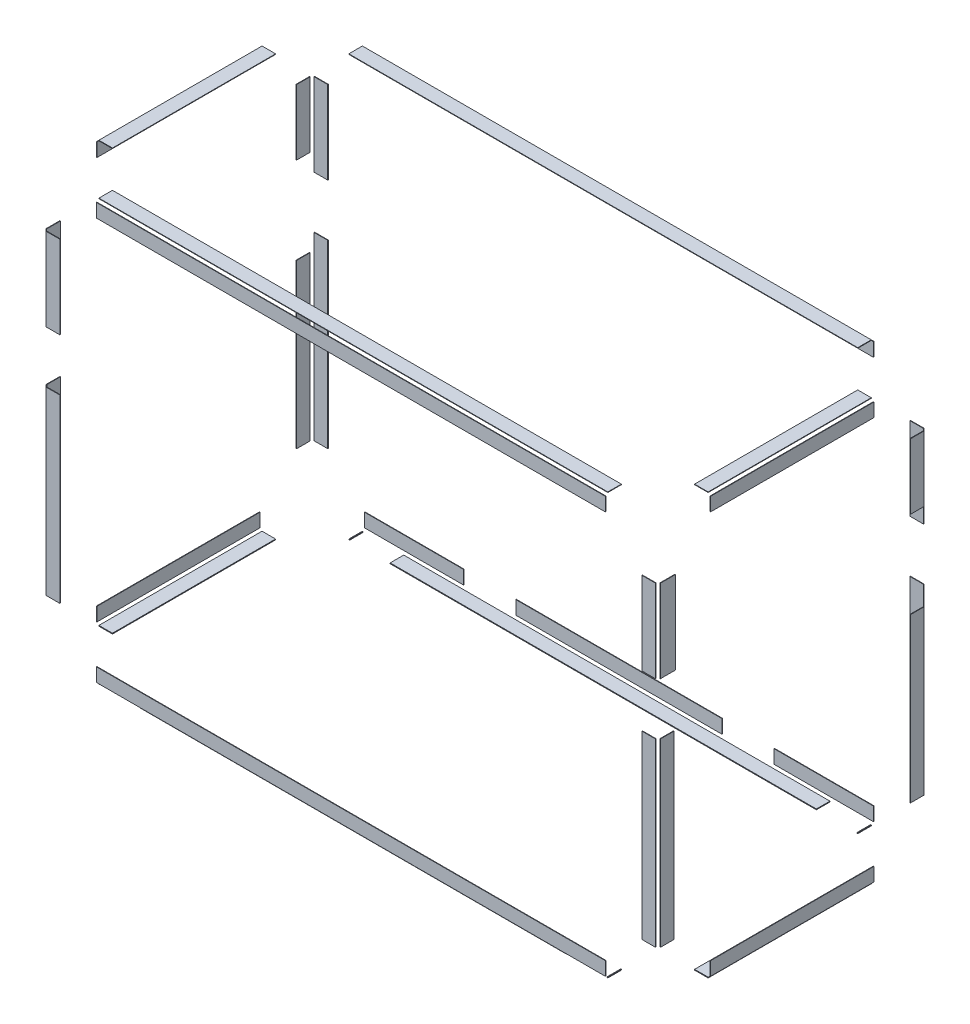
from build123d import *

# Parameters (mm, degrees)
SKETCH1_W              = 506.684
SKETCH1_H              = 42.1005
BOSS_EXTRUDE1_DEPTH    = 1.5875
SKETCH1_W_2            = 42.1005
SKETCH1_H_2            = 203.1375
BOSS_EXTRUDE1_2_DEPTH  = 1.5875
SKETCH1_W_3            = 47.107097302
SKETCH1_H_3            = 257.1125
BOSS_EXTRUDE1_3_DEPTH  = 1.5875
SKETCH1_H_4            = 560.4685
BOSS_EXTRUDE1_4_DEPTH  = 1.5875
SKETCH1_W_4            = 506.683999998
BOSS_EXTRUDE1_5_DEPTH  = 1.5875
SKETCH1_H_5            = 506.4935
BOSS_EXTRUDE1_6_DEPTH  = 1.5875
SKETCH2_W              = 1580.506
SKETCH2_H              = 42.1005
BOSS_EXTRUDE2_DEPTH    = 1.5875
BOSS_EXTRUDE2_2_DEPTH  = 1.5875
SKETCH2_W_2            = 42.1005
SKETCH2_H_2            = 257.1125
BOSS_EXTRUDE2_3_DEPTH  = 1.5875
SKETCH2_H_3            = 560.4685
BOSS_EXTRUDE2_4_DEPTH  = 1.5875
BOSS_EXTRUDE2_5_DEPTH  = 1.5875
BOSS_EXTRUDE2_6_DEPTH  = 1.5875
SKETCH3_W              = 506.684
SKETCH3_H              = 42.1005
BOSS_EXTRUDE3_DEPTH    = 1.5875
SKETCH3_W_2            = 42.672
SKETCH3_H_2            = 257.1125
BOSS_EXTRUDE3_2_DEPTH  = 1.5875
SKETCH3_W_3            = 42.1005
SKETCH3_H_3            = 560.4685
BOSS_EXTRUDE3_3_DEPTH  = 1.5875
BOSS_EXTRUDE3_4_DEPTH  = 1.5875
SKETCH3_H_4            = 506.4935
BOSS_EXTRUDE3_5_DEPTH  = 1.5875
SKETCH3_H_5            = 203.1375
BOSS_EXTRUDE3_6_DEPTH  = 1.5875
SKETCH5_W              = 308.2905
SKETCH5_H              = 42.1005
BOSS_EXTRUDE4_DEPTH    = 1.5875
SKETCH5_W_2            = 640.075
BOSS_EXTRUDE4_2_DEPTH  = 1.5875
BOSS_EXTRUDE4_3_DEPTH  = 1.5875
SKETCH5_W_3            = 42.1005
SKETCH5_H_2            = 257.1125
BOSS_EXTRUDE4_4_DEPTH  = 1.5875
SKETCH5_H_3            = 560.4685
BOSS_EXTRUDE4_5_DEPTH  = 1.5875
BOSS_EXTRUDE4_6_DEPTH  = 1.5875
BOSS_EXTRUDE4_7_DEPTH  = 1.5875
BOSS_EXTRUDE4_8_DEPTH  = 1.5875
BOSS_EXTRUDE4_9_DEPTH  = 1.5875
BOSS_EXTRUDE4_10_DEPTH = 1.5875
SKETCH6_W              = 1580.506
SKETCH6_H              = 42.1005
BOSS_EXTRUDE5_DEPTH    = 1.5875
SKETCH6_W_2            = 42.1005
SKETCH6_H_2            = 506.684
BOSS_EXTRUDE5_2_DEPTH  = 1.5875
BOSS_EXTRUDE5_3_DEPTH  = 1.5875
BOSS_EXTRUDE5_4_DEPTH  = 1.5875
SKETCH7_W              = 2.073
SKETCH7_H              = 42.1005
BOSS_EXTRUDE6_DEPTH    = 2.36
SKETCH7_W_2            = 1323.64
BOSS_EXTRUDE6_2_DEPTH  = 2.36
BOSS_EXTRUDE6_3_DEPTH  = 2.36
SKETCH7_W_3            = 42.1005
SKETCH7_H_2            = 506.684
BOSS_EXTRUDE6_4_DEPTH  = 2.36
BOSS_EXTRUDE6_5_DEPTH  = 2.36
BOSS_EXTRUDE6_6_DEPTH  = 2.36
BOSS_EXTRUDE6_7_DEPTH  = 2.36
BOSS_EXTRUDE6_8_DEPTH  = 2.36


with BuildPart() as part:
    # Sketch1 → Boss-Extrude1 (new body)
    with BuildSketch(Plane(origin=(965.857215111, 0, 0), x_dir=(0, 0, -1), z_dir=(1, 0, 0))):
        with Locations((11.055781125, 630.148409052)):
            Rectangle(SKETCH1_W, SKETCH1_H)
    extrude(amount=BOSS_EXTRUDE1_DEPTH)


with BuildPart() as body_2:
    # Sketch1 → Boss-Extrude1 2 (new body)
    with BuildSketch(Plane(origin=(965.857215111, 0, 0), x_dir=(0, 0, -1), z_dir=(1, 0, 0))):
        with Locations((399.144781125, 393.832659052)):
            Rectangle(SKETCH1_W_2, SKETCH1_H_2)
    extrude(amount=BOSS_EXTRUDE1_2_DEPTH)


with BuildPart() as body_3:
    # Sketch1 → Boss-Extrude1 3 (new body)
    with BuildSketch(Plane(origin=(965.857215111, 0, 0), x_dir=(0, 0, -1), z_dir=(1, 0, 0))):
        with Locations((-375.101420224, 366.845159052)):
            Rectangle(SKETCH1_W_3, SKETCH1_H_3)
    extrude(amount=BOSS_EXTRUDE1_3_DEPTH)


with BuildPart() as body_4:
    # Sketch1 → Boss-Extrude1 4 (new body)
    with BuildSketch(Plane(origin=(965.857215111, 0, 0), x_dir=(0, 0, -1), z_dir=(1, 0, 0))):
        with Locations((-377.033218875, -203.870340948)):
            Rectangle(SKETCH1_W_2, SKETCH1_H_4)
    extrude(amount=BOSS_EXTRUDE1_4_DEPTH)


with BuildPart() as body_5:
    # Sketch1 → Boss-Extrude1 5 (new body)
    with BuildSketch(Plane(origin=(965.857215111, 0, 0), x_dir=(0, 0, -1), z_dir=(1, 0, 0))):
        with Locations((11.055781126, -618.851590948)):
            Rectangle(SKETCH1_W_4, SKETCH1_H)
    extrude(amount=BOSS_EXTRUDE1_5_DEPTH)


with BuildPart() as body_6:
    # Sketch1 → Boss-Extrude1 6 (new body)
    with BuildSketch(Plane(origin=(965.857215111, 0, 0), x_dir=(0, 0, -1), z_dir=(1, 0, 0))):
        with Locations((399.144781125, -230.857840948)):
            Rectangle(SKETCH1_W_2, SKETCH1_H_5)
    extrude(amount=BOSS_EXTRUDE1_6_DEPTH)


with BuildPart() as body_7:
    # Sketch2 → Boss-Extrude2 (new body)
    with BuildSketch(Plane.XY.offset(404.211218875)):
        with Locations((13.679215111, 630.148409052)):
            Rectangle(SKETCH2_W, SKETCH2_H)
    extrude(amount=BOSS_EXTRUDE2_DEPTH)


with BuildPart() as body_8:
    # Sketch2 → Boss-Extrude2 2 (new body)
    with BuildSketch(Plane.XY.offset(404.211218875)):
        with Locations((13.679215111, -618.851590948)):
            Rectangle(SKETCH2_W, SKETCH2_H)
    extrude(amount=BOSS_EXTRUDE2_2_DEPTH)


with BuildPart() as body_9:
    # Sketch2 → Boss-Extrude2 3 (new body)
    with BuildSketch(Plane.XY.offset(404.211218875)):
        with Locations((938.679215111, 366.845159052)):
            Rectangle(SKETCH2_W_2, SKETCH2_H_2)
    extrude(amount=BOSS_EXTRUDE2_3_DEPTH)


with BuildPart() as body_10:
    # Sketch2 → Boss-Extrude2 4 (new body)
    with BuildSketch(Plane.XY.offset(404.211218875)):
        with Locations((938.679215111, -203.870340948)):
            Rectangle(SKETCH2_W_2, SKETCH2_H_3)
    extrude(amount=BOSS_EXTRUDE2_4_DEPTH)


with BuildPart() as body_11:
    # Sketch2 → Boss-Extrude2 5 (new body)
    with BuildSketch(Plane.XY.offset(404.211218875)):
        with Locations((-911.320784889, -203.870340948)):
            Rectangle(SKETCH2_W_2, SKETCH2_H_3)
    extrude(amount=BOSS_EXTRUDE2_5_DEPTH)


with BuildPart() as body_12:
    # Sketch2 → Boss-Extrude2 6 (new body)
    with BuildSketch(Plane.XY.offset(404.211218875)):
        with Locations((-911.320784889, 366.845159052)):
            Rectangle(SKETCH2_W_2, SKETCH2_H_2)
    extrude(amount=BOSS_EXTRUDE2_6_DEPTH)


with BuildPart() as body_13:
    # Sketch3 → Boss-Extrude3 (new body)
    with BuildSketch(Plane.ZY.offset(938.498784889)):
        with Locations((-11.055781125, 630.148409052)):
            Rectangle(SKETCH3_W, SKETCH3_H)
    extrude(amount=BOSS_EXTRUDE3_DEPTH)


with BuildPart() as body_14:
    # Sketch3 → Boss-Extrude3 2 (new body)
    with BuildSketch(Plane.ZY.offset(938.498784889)):
        with Locations((377.318968875, 366.845159052)):
            Rectangle(SKETCH3_W_2, SKETCH3_H_2)
    extrude(amount=BOSS_EXTRUDE3_2_DEPTH)


with BuildPart() as body_15:
    # Sketch3 → Boss-Extrude3 3 (new body)
    with BuildSketch(Plane.ZY.offset(938.498784889)):
        with Locations((377.033218875, -203.870340948)):
            Rectangle(SKETCH3_W_3, SKETCH3_H_3)
    extrude(amount=BOSS_EXTRUDE3_3_DEPTH)


with BuildPart() as body_16:
    # Sketch3 → Boss-Extrude3 4 (new body)
    with BuildSketch(Plane.ZY.offset(938.498784889)):
        Polygon((-264.397781125, -597.801340948), (242.286218875, -597.801340948), (242.286218873, -639.901840948), (-264.397781125, -639.901840948), align=None)
    extrude(amount=BOSS_EXTRUDE3_4_DEPTH)


with BuildPart() as body_17:
    # Sketch3 → Boss-Extrude3 5 (new body)
    with BuildSketch(Plane.ZY.offset(938.498784889)):
        with Locations((-399.144781125, -230.857840948)):
            Rectangle(SKETCH3_W_3, SKETCH3_H_4)
    extrude(amount=BOSS_EXTRUDE3_5_DEPTH)


with BuildPart() as body_18:
    # Sketch3 → Boss-Extrude3 6 (new body)
    with BuildSketch(Plane.ZY.offset(938.498784889)):
        with Locations((-399.144781125, 393.832659052)):
            Rectangle(SKETCH3_W_3, SKETCH3_H_5)
    extrude(amount=BOSS_EXTRUDE3_6_DEPTH)


with BuildPart() as body_19:
    # Sketch5 → Boss-Extrude4 (new body)
    with BuildSketch(Plane(origin=(0, 0, -426.322781125), x_dir=(-1, 0, 0), z_dir=(0, 0, -1))):
        with Locations((-649.786965111, 630.148409052)):
            Rectangle(SKETCH5_W, SKETCH5_H)
    extrude(amount=BOSS_EXTRUDE4_DEPTH)


with BuildPart() as body_20:
    # Sketch5 → Boss-Extrude4 2 (new body)
    with BuildSketch(Plane(origin=(0, 0, -426.322781125), x_dir=(-1, 0, 0), z_dir=(0, 0, -1))):
        with Locations((-13.679215111, 630.148409052)):
            Rectangle(SKETCH5_W_2, SKETCH5_H)
    extrude(amount=BOSS_EXTRUDE4_2_DEPTH)


with BuildPart() as body_21:
    # Sketch5 → Boss-Extrude4 3 (new body)
    with BuildSketch(Plane(origin=(0, 0, -426.322781125), x_dir=(-1, 0, 0), z_dir=(0, 0, -1))):
        with Locations((622.428534889, 630.148409052)):
            Rectangle(SKETCH5_W, SKETCH5_H)
    extrude(amount=BOSS_EXTRUDE4_3_DEPTH)


with BuildPart() as body_22:
    # Sketch5 → Boss-Extrude4 4 (new body)
    with BuildSketch(Plane(origin=(0, 0, -426.322781125), x_dir=(-1, 0, 0), z_dir=(0, 0, -1))):
        with Locations((911.320784889, 366.845159052)):
            Rectangle(SKETCH5_W_3, SKETCH5_H_2)
    extrude(amount=BOSS_EXTRUDE4_4_DEPTH)


with BuildPart() as body_23:
    # Sketch5 → Boss-Extrude4 5 (new body)
    with BuildSketch(Plane(origin=(0, 0, -426.322781125), x_dir=(-1, 0, 0), z_dir=(0, 0, -1))):
        with Locations((911.320784889, -203.870340948)):
            Rectangle(SKETCH5_W_3, SKETCH5_H_3)
    extrude(amount=BOSS_EXTRUDE4_5_DEPTH)


with BuildPart() as body_24:
    # Sketch5 → Boss-Extrude4 6 (new body)
    with BuildSketch(Plane(origin=(0, 0, -426.322781125), x_dir=(-1, 0, 0), z_dir=(0, 0, -1))):
        with Locations((622.428534889, -618.851590948)):
            Rectangle(SKETCH5_W, SKETCH5_H)
    extrude(amount=BOSS_EXTRUDE4_6_DEPTH)


with BuildPart() as body_25:
    # Sketch5 → Boss-Extrude4 7 (new body)
    with BuildSketch(Plane(origin=(0, 0, -426.322781125), x_dir=(-1, 0, 0), z_dir=(0, 0, -1))):
        with Locations((-13.679215111, -618.851590948)):
            Rectangle(SKETCH5_W_2, SKETCH5_H)
    extrude(amount=BOSS_EXTRUDE4_7_DEPTH)


with BuildPart() as body_26:
    # Sketch5 → Boss-Extrude4 8 (new body)
    with BuildSketch(Plane(origin=(0, 0, -426.322781125), x_dir=(-1, 0, 0), z_dir=(0, 0, -1))):
        with Locations((-649.786965111, -618.851590948)):
            Rectangle(SKETCH5_W, SKETCH5_H)
    extrude(amount=BOSS_EXTRUDE4_8_DEPTH)


with BuildPart() as body_27:
    # Sketch5 → Boss-Extrude4 9 (new body)
    with BuildSketch(Plane(origin=(0, 0, -426.322781125), x_dir=(-1, 0, 0), z_dir=(0, 0, -1))):
        with Locations((-938.679215111, 366.845159052)):
            Rectangle(SKETCH5_W_3, SKETCH5_H_2)
    extrude(amount=BOSS_EXTRUDE4_9_DEPTH)


with BuildPart() as body_28:
    # Sketch5 → Boss-Extrude4 10 (new body)
    with BuildSketch(Plane(origin=(0, 0, -426.322781125), x_dir=(-1, 0, 0), z_dir=(0, 0, -1))):
        with Locations((-938.679215111, -203.870340948)):
            Rectangle(SKETCH5_W_3, SKETCH5_H_3)
    extrude(amount=BOSS_EXTRUDE4_10_DEPTH)


with BuildPart() as body_29:
    # Sketch6 → Boss-Extrude5 (new body)
    with BuildSketch(Plane(origin=(0, 657.326409052, 0), x_dir=(1, 0, 0), z_dir=(0, 1, 0))):
        with Locations((13.679215111, 399.144781125)):
            Rectangle(SKETCH6_W, SKETCH6_H)
    extrude(amount=BOSS_EXTRUDE5_DEPTH)


with BuildPart() as body_30:
    # Sketch6 → Boss-Extrude5 2 (new body)
    with BuildSketch(Plane(origin=(0, 657.326409052, 0), x_dir=(1, 0, 0), z_dir=(0, 1, 0))):
        with Locations((938.679215111, 11.055781125)):
            Rectangle(SKETCH6_W_2, SKETCH6_H_2)
    extrude(amount=BOSS_EXTRUDE5_2_DEPTH)


with BuildPart() as body_31:
    # Sketch6 → Boss-Extrude5 3 (new body)
    with BuildSketch(Plane(origin=(0, 657.326409052, 0), x_dir=(1, 0, 0), z_dir=(0, 1, 0))):
        with Locations((13.679215111, -377.033218875)):
            Rectangle(SKETCH6_W, SKETCH6_H)
    extrude(amount=BOSS_EXTRUDE5_3_DEPTH)


with BuildPart() as body_32:
    # Sketch6 → Boss-Extrude5 4 (new body)
    with BuildSketch(Plane(origin=(0, 657.326409052, 0), x_dir=(1, 0, 0), z_dir=(0, 1, 0))):
        with Locations((-911.320784889, 11.055781125)):
            Rectangle(SKETCH6_W_2, SKETCH6_H_2)
    extrude(amount=BOSS_EXTRUDE5_4_DEPTH)


with BuildPart() as body_33:
    # Sketch7 → Boss-Extrude6 (new body)
    with BuildSketch(Plane.XZ.offset(646.029590948)):
        with Locations((-775.537284889, 377.033218875)):
            Rectangle(SKETCH7_W, SKETCH7_H)
    extrude(amount=BOSS_EXTRUDE6_DEPTH)


with BuildPart() as body_34:
    # Sketch7 → Boss-Extrude6 2 (new body)
    with BuildSketch(Plane.XZ.offset(646.029590948)):
        with Locations((13.679215111, 377.033218875)):
            Rectangle(SKETCH7_W_2, SKETCH7_H)
    extrude(amount=BOSS_EXTRUDE6_2_DEPTH)


with BuildPart() as body_35:
    # Sketch7 → Boss-Extrude6 3 (new body)
    with BuildSketch(Plane.XZ.offset(646.029590948)):
        with Locations((802.895715111, 377.033218875)):
            Rectangle(SKETCH7_W, SKETCH7_H)
    extrude(amount=BOSS_EXTRUDE6_3_DEPTH)


with BuildPart() as body_36:
    # Sketch7 → Boss-Extrude6 4 (new body)
    with BuildSketch(Plane.XZ.offset(646.029590948)):
        with Locations((938.679215111, -11.055781125)):
            Rectangle(SKETCH7_W_3, SKETCH7_H_2)
    extrude(amount=BOSS_EXTRUDE6_4_DEPTH)


with BuildPart() as body_37:
    # Sketch7 → Boss-Extrude6 5 (new body)
    with BuildSketch(Plane.XZ.offset(646.029590948)):
        with Locations((802.895715111, -399.144781125)):
            Rectangle(SKETCH7_W, SKETCH7_H)
    extrude(amount=BOSS_EXTRUDE6_5_DEPTH)


with BuildPart() as body_38:
    # Sketch7 → Boss-Extrude6 6 (new body)
    with BuildSketch(Plane.XZ.offset(646.029590948)):
        with Locations((13.679215111, -399.144781125)):
            Rectangle(SKETCH7_W_2, SKETCH7_H)
    extrude(amount=BOSS_EXTRUDE6_6_DEPTH)


with BuildPart() as body_39:
    # Sketch7 → Boss-Extrude6 7 (new body)
    with BuildSketch(Plane.XZ.offset(646.029590948)):
        with Locations((-775.537284889, -399.144781125)):
            Rectangle(SKETCH7_W, SKETCH7_H)
    extrude(amount=BOSS_EXTRUDE6_7_DEPTH)


with BuildPart() as body_40:
    # Sketch7 → Boss-Extrude6 8 (new body)
    with BuildSketch(Plane.XZ.offset(646.029590948)):
        with Locations((-911.320784889, -11.055781125)):
            Rectangle(SKETCH7_W_3, SKETCH7_H_2)
    extrude(amount=BOSS_EXTRUDE6_8_DEPTH)


solid = Compound([part.part, body_2.part, body_3.part, body_4.part, body_5.part, body_6.part, body_7.part, body_8.part, body_9.part, body_10.part, body_11.part, body_12.part, body_13.part, body_14.part, body_15.part, body_16.part, body_17.part, body_18.part, body_19.part, body_20.part, body_21.part, body_22.part, body_23.part, body_24.part, body_25.part, body_26.part, body_27.part, body_28.part, body_29.part, body_30.part, body_31.part, body_32.part, body_33.part, body_34.part, body_35.part, body_36.part, body_37.part, body_38.part, body_39.part, body_40.part])
